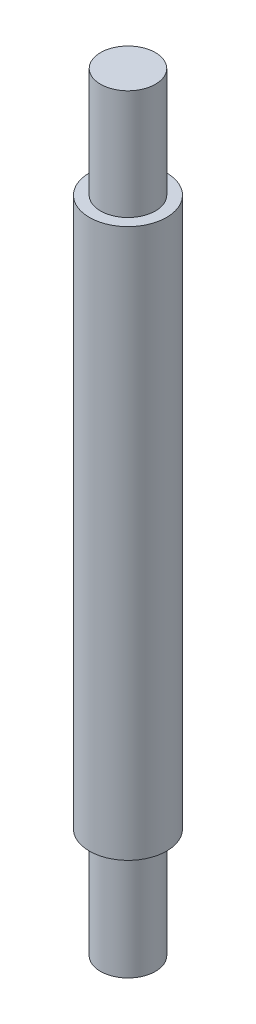
from build123d import *

# Parameters (mm, degrees)
SKETCH1_R           = 3.515
BOSS_EXTRUDE1_DEPTH = 50
SKETCH2_R           = 2.5
BOSS_EXTRUDE2_DEPTH = 10
SKETCH3_R           = 2.5
BOSS_EXTRUDE5_DEPTH = 60


with BuildPart() as part:
    # Sketch1 → Boss-Extrude1 (new body)
    with BuildSketch(Plane(origin=(0, 0, 0), x_dir=(1, 0, 0), z_dir=(0, 1, 0))):
        Circle(SKETCH1_R)
    extrude(amount=BOSS_EXTRUDE1_DEPTH)

    # Sketch2 → Boss-Extrude2 (add)
    with BuildSketch(Plane(origin=(0, 0, 0), x_dir=(1, 0, 0), z_dir=(0, 1, 0))):
        Circle(SKETCH2_R)
    extrude(amount=-BOSS_EXTRUDE2_DEPTH)

    # Sketch3 → Boss-Extrude5 (add)
    with BuildSketch(Plane(origin=(0, 0, 0), x_dir=(1, 0, 0), z_dir=(0, 1, 0))):
        Circle(SKETCH3_R)
    extrude(amount=BOSS_EXTRUDE5_DEPTH)


solid = part.part
